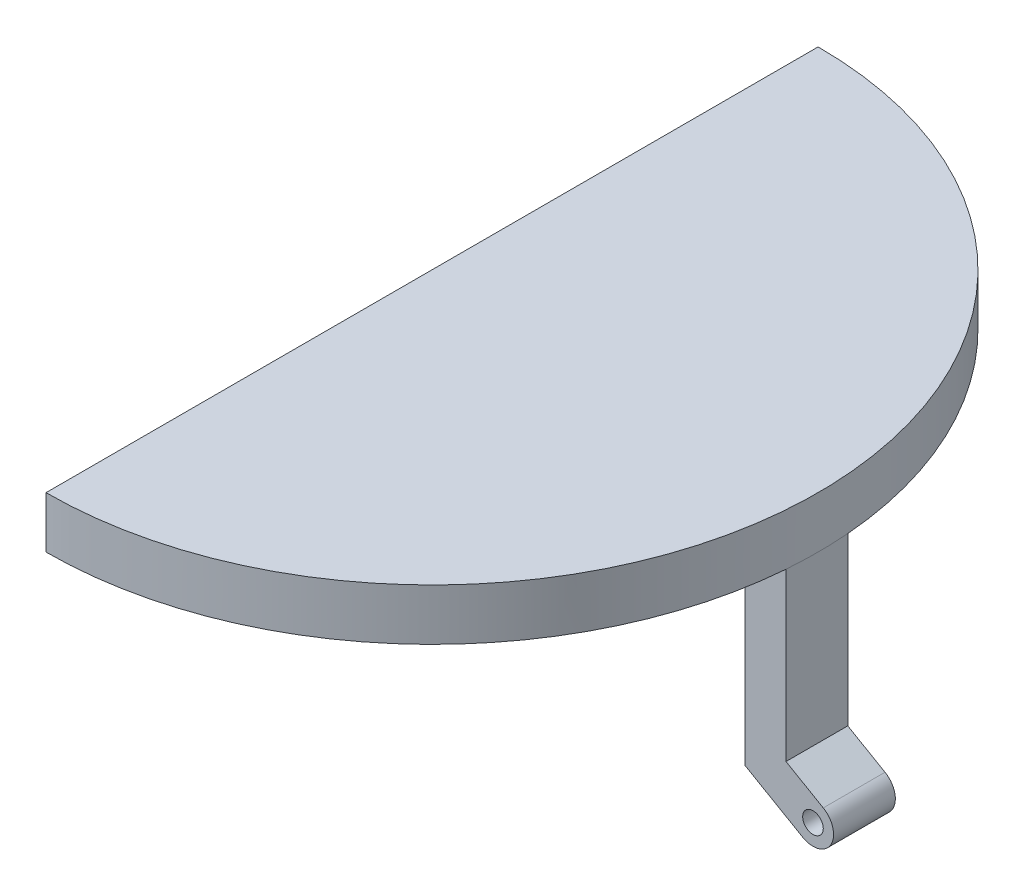
from build123d import *

# Parameters (mm, degrees)
AUFSATZ_LINEAR_AUSTRAGEN1_DEPTH = 5
AUFSATZ_LINEAR_AUSTRAGEN2_DEPTH = 6
SKIZZE13_R                      = 1
SCHNITT_LINEAR_AUSTRAGEN1_DEPTH = 6


with BuildPart() as part:
    # Skizze1 → Aufsatz-Linear austragen1 (new body)
    with BuildSketch(Plane(origin=(0, 0, 0), x_dir=(1, 0, 0), z_dir=(0, 1, 0))):
        with BuildLine():
            Line((0, 0), (0, -75))
            ThreePointArc((0, -75), (37.5, -37.5), (0, 0))
        make_face()
    extrude(amount=AUFSATZ_LINEAR_AUSTRAGEN1_DEPTH)

    # Skizze12 → Aufsatz-Linear austragen2 (add)
    with BuildSketch(Plane(origin=(37.379807383, 0, 40.5), x_dir=(1, 0, 0), z_dir=(0, 0, 1))):
        with BuildLine():
            Line((0, 0), (0, -16.177830011))
            Line((0, -16.177830011), (3.620192617, -18.267949192))
            ThreePointArc((3.620192617, -18.267949192), (4.352243424, -21), (1.620192617, -21.732050808))
            Line((1.620192617, -21.732050808), (-4, -18.487231087))
            Line((-4, -18.487231087), (-4, 0))
            Line((-4, 0), (0, 0))
        make_face()
    extrude(amount=-AUFSATZ_LINEAR_AUSTRAGEN2_DEPTH)

    # Skizze13 → Schnitt-Linear austragen1 (cut)
    with BuildSketch(Plane(origin=(37.379807383, 0, 40.5), x_dir=(1, 0, 0), z_dir=(0, 0, 1))):
        with Locations((2.620192617, -20)):
            Circle(SKIZZE13_R)
    extrude(amount=-SCHNITT_LINEAR_AUSTRAGEN1_DEPTH, mode=Mode.SUBTRACT)


solid = part.part
